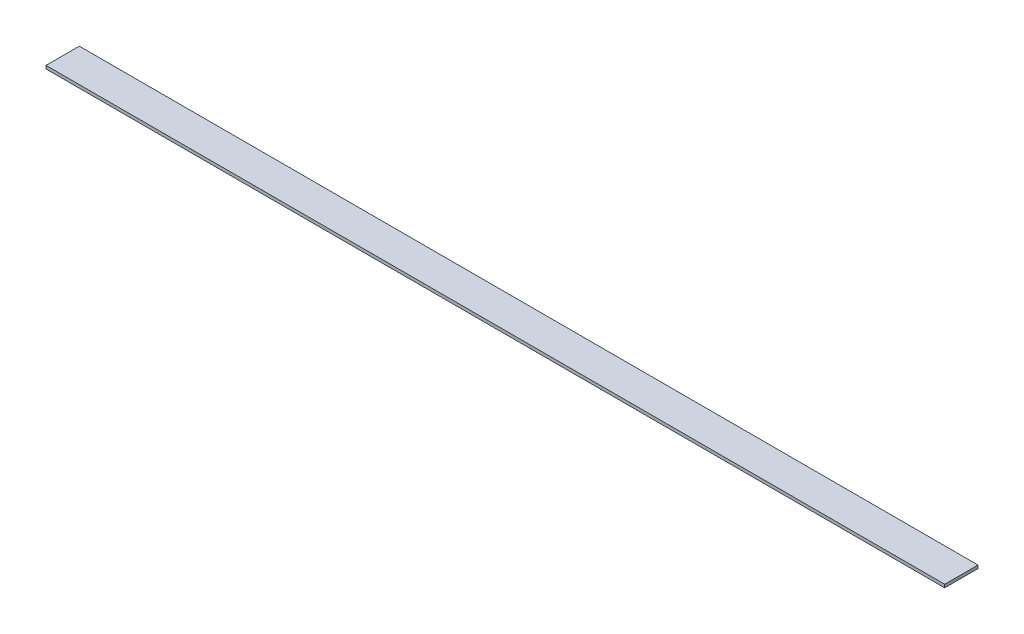
from build123d import *

# Parameters (mm, degrees)
SKETCH1_W           = 917.575
SKETCH1_H           = 34
BOSS_EXTRUDE1_DEPTH = 3.175


with BuildPart() as part:
    # Sketch1 → Boss-Extrude1 (new body)
    with BuildSketch(Plane(origin=(0, 0, 0), x_dir=(1, 0, 0), z_dir=(0, 1, 0))):
        with Locations((458.7875, 17)):
            Rectangle(SKETCH1_W, SKETCH1_H)
    extrude(amount=BOSS_EXTRUDE1_DEPTH)


solid = part.part
